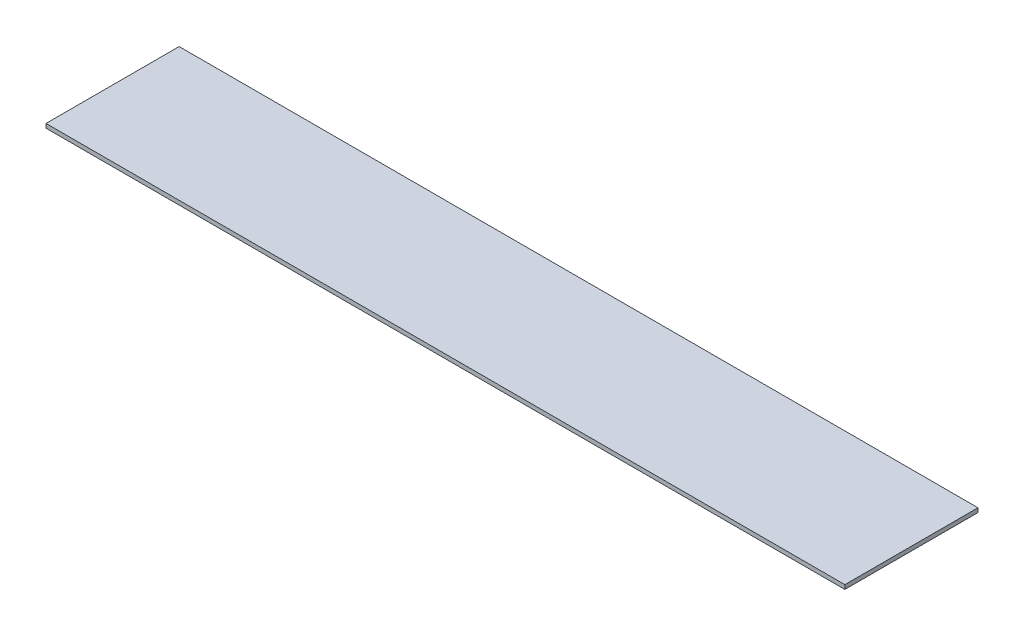
from build123d import *

# Parameters (mm, degrees)
SKETCH1_W           = 609.6
SKETCH1_H           = 101.6
BOSS_EXTRUDE1_DEPTH = 3.175


with BuildPart() as part:
    # Sketch1 → Boss-Extrude1 (new body)
    with BuildSketch(Plane.XZ.offset(80.26236602)):
        with Locations((304.8, 50.8)):
            Rectangle(SKETCH1_W, SKETCH1_H)
    extrude(amount=BOSS_EXTRUDE1_DEPTH)


solid = part.part
